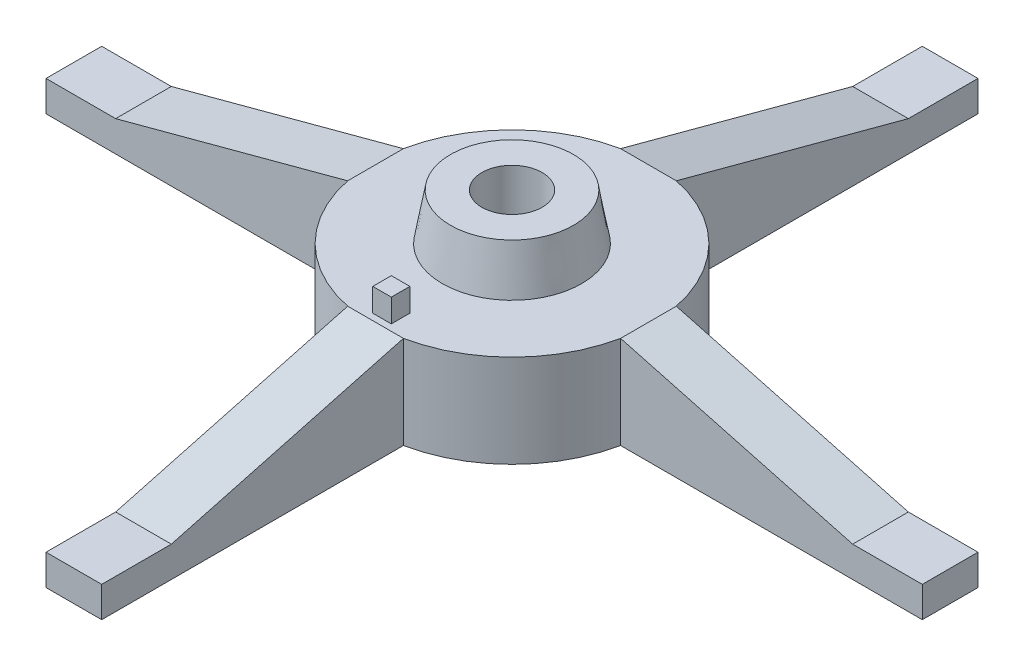
from build123d import *

# Parameters (mm, degrees)
SKETCH1_R           = 30
BASE_DEPTH          = 20
BOSS_EXTRUDE1_DEPTH = 20
CUT_EXTRUDE1_DEPTH  = 37
CIRPATTERN1_COUNT   = 4
BOSS_EXTRUDE2_START = 20
SKETCH1_10_R        = 15
BOSS_EXTRUDE2_DEPTH = 10
BOSS_EXTRUDE2_TAPER = 10
SKETCH1_11_R        = 6.5
CUT_EXTRUDE2_DEPTH  = 31.0000001
SKETCH1_12_W        = 4
SKETCH1_12_H        = 4
BOSS_EXTRUDE3_DEPTH = 25


with BuildPart() as part:
    # Sketch1 → Base (new body)
    with BuildSketch(Plane(origin=(0, 0, 0), x_dir=(1, 0, 0), z_dir=(0, 1, 0))):
        with Locations(Location((0, 0, 0), (0, 0, 270))):  # turned: the seam where the file's is
            Circle(SKETCH1_R)
    extrude(amount=BASE_DEPTH)

    # Sketch1_8 → Boss-Extrude1 (add)
    with BuildSketch(Plane(origin=(0, 0, 0), x_dir=(1, 0, 0), z_dir=(0, 1, 0))):
        with BuildLine():
            ThreePointArc((6, -29.393876913), (0, -30), (-6, -29.393876913))
            Line((-6, -29.393876913), (-6, -94.393876913))
            Line((-6, -94.393876913), (6, -94.393876913))
            Line((6, -94.393876913), (6, -29.393876913))
        make_face()
    boss_extrude1 = extrude(amount=BOSS_EXTRUDE1_DEPTH)

    # Sketch2 → Cut-Extrude1 (cut, through all)
    with BuildSketch(Plane.ZY.offset(6)):
        Polygon((29.393876913, 20), (94.393876913, 20), (94.393876913, 6.602540378), (79.393876913, 6.602540378), align=None)
    cut_extrude1 = extrude(amount=-CUT_EXTRUDE1_DEPTH, mode=Mode.SUBTRACT)

    # CirPattern1: Boss-Extrude1, Cut-Extrude1 ×4 about axis
    cirpattern1_axis = Axis((0, 0, 0), (0, 1, 0))
    add([boss_extrude1.rotate(cirpattern1_axis, i * 360 / CIRPATTERN1_COUNT) for i in range(1, CIRPATTERN1_COUNT)])
    add([cut_extrude1.rotate(cirpattern1_axis, i * 360 / CIRPATTERN1_COUNT) for i in range(1, CIRPATTERN1_COUNT)], mode=Mode.SUBTRACT)

    # Sketch1_10 → Boss-Extrude2 (add)
    with BuildSketch(Plane(origin=(0, 0, 0), x_dir=(1, 0, 0), z_dir=(0, 1, 0)).offset(BOSS_EXTRUDE2_START)):
        Circle(SKETCH1_10_R)
    extrude(amount=BOSS_EXTRUDE2_DEPTH, taper=BOSS_EXTRUDE2_TAPER)

    # Sketch1_11 → Cut-Extrude2 (cut, through all)
    with BuildSketch(Plane(origin=(0, 0, 0), x_dir=(1, 0, 0), z_dir=(0, 1, 0))):
        with Locations(Location((0, 0, 0), (0, 0, 270))):  # turned: the seam where the file's is
            Circle(SKETCH1_11_R)
    extrude(amount=CUT_EXTRUDE2_DEPTH, mode=Mode.SUBTRACT)

    # Sketch1_12 → Boss-Extrude3 (add)
    with BuildSketch(Plane(origin=(0, 0, 0), x_dir=(1, 0, 0), z_dir=(0, 1, 0))):
        with Locations((0, -26)):
            Rectangle(SKETCH1_12_W, SKETCH1_12_H)
    extrude(amount=BOSS_EXTRUDE3_DEPTH)


solid = part.part
